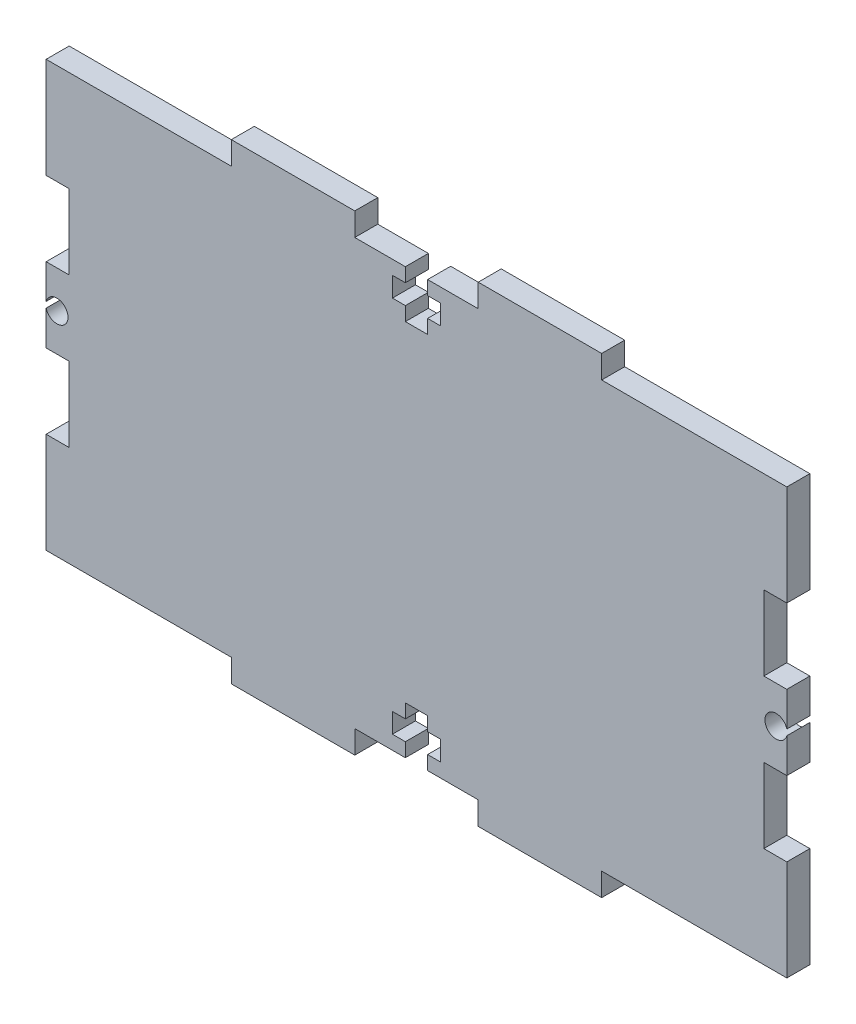
from build123d import *

# Parameters (mm, degrees)
SKETCH1_W           = 96.52
SKETCH1_H           = 55.42
BOSS_EXTRUDE1_DEPTH = 3
SKETCH2_W           = 48.26
SKETCH2_H           = 3
BOSS_EXTRUDE2_DEPTH = 3
SKETCH4_W           = 3
SKETCH4_H           = 29.21
CUT_EXTRUDE1_DEPTH  = 3
SKETCH5_W           = 16.086666666
SKETCH5_H           = 3
CUT_EXTRUDE2_DEPTH  = 3
SKETCH6_W           = 3
SKETCH6_H           = 9.737913064
BOSS_EXTRUDE3_DEPTH = 3
SKETCH7_W           = 2.9
SKETCH7_H           = 3
CUT_EXTRUDE3_DEPTH  = 6.2
SKETCH9_W           = 6.27
SKETCH9_H           = 2.573555094
CUT_EXTRUDE4_DEPTH  = 3
SKETCH10_R          = 1.45
CUT_EXTRUDE5_DEPTH  = 3


with BuildPart() as part:
    # Sketch1 → Boss-Extrude1 (new body)
    with BuildSketch(Plane.XY):
        Rectangle(SKETCH1_W, SKETCH1_H)
    extrude(amount=BOSS_EXTRUDE1_DEPTH)

    # Sketch2 → Boss-Extrude2 (add)
    with BuildSketch(Plane(origin=(0, 27.71, 0), x_dir=(1, 0, 0), z_dir=(0, 1, 0))):
        with Locations((0, -1.5)):
            Rectangle(SKETCH2_W, SKETCH2_H)
    boss_extrude2 = extrude(amount=BOSS_EXTRUDE2_DEPTH)

    # Mirror1: Boss-Extrude2 across plane
    add(boss_extrude2.mirror(Plane.ZX))

    # Sketch4 → Cut-Extrude1 (cut)
    with BuildSketch(Plane(origin=(48.26, 0, 0), x_dir=(0, 0, -1), z_dir=(1, 0, 0))):
        with Locations((-1.5, 0)):
            Rectangle(SKETCH4_W, SKETCH4_H)
    cut_extrude1 = extrude(amount=-CUT_EXTRUDE1_DEPTH, mode=Mode.SUBTRACT)

    # Mirror2: Cut-Extrude1 across plane
    add(cut_extrude1.mirror(Plane(origin=(0, 0, 0), x_dir=(0, 0, 1), z_dir=(1, 0, 0))), mode=Mode.SUBTRACT)

    # Sketch5 → Cut-Extrude2 (cut)
    with BuildSketch(Plane(origin=(0, 30.71, 0), x_dir=(1, 0, 0), z_dir=(0, 1, 0))):
        with Locations((0, -1.5)):
            Rectangle(SKETCH5_W, SKETCH5_H)
    cut_extrude2 = extrude(amount=-CUT_EXTRUDE2_DEPTH, mode=Mode.SUBTRACT)

    # Mirror3: Cut-Extrude2 across plane
    add(cut_extrude2.mirror(Plane.ZX), mode=Mode.SUBTRACT)

    # Sketch6 → Boss-Extrude3 (add)
    with BuildSketch(Plane.ZY.offset(45.26)):
        with Locations((1.5, 0)):
            Rectangle(SKETCH6_W, SKETCH6_H)
    boss_extrude3 = extrude(amount=BOSS_EXTRUDE3_DEPTH)

    # Mirror4: Boss-Extrude3 across plane
    add(boss_extrude3.mirror(Plane(origin=(0, 0, 0), x_dir=(0, 0, 1), z_dir=(1, 0, 0))))

    # Sketch7 → Cut-Extrude3 (cut)
    with BuildSketch(Plane.XZ.offset(27.71)):
        with Locations((0, 1.5)):
            Rectangle(SKETCH7_W, SKETCH7_H)
    cut_extrude3 = extrude(amount=-CUT_EXTRUDE3_DEPTH, mode=Mode.SUBTRACT)

    # Sketch9 → Cut-Extrude4 (cut)
    with BuildSketch(Plane(origin=(0, 0, 0), x_dir=(-1, 0, 0), z_dir=(0, 0, -1))):
        with Locations((0, -24.61)):
            Rectangle(SKETCH9_W, SKETCH9_H)
    cut_extrude4 = extrude(amount=-CUT_EXTRUDE4_DEPTH, mode=Mode.SUBTRACT)

    # Mirror5: Cut-Extrude3 across plane
    add(cut_extrude3.mirror(Plane.ZX), mode=Mode.SUBTRACT)

    # Mirror6: Cut-Extrude4 across plane
    add(cut_extrude4.mirror(Plane.ZX), mode=Mode.SUBTRACT)

    # Sketch10 → Cut-Extrude5 (cut)
    with BuildSketch(Plane(origin=(0, 0, 0), x_dir=(-1, 0, 0), z_dir=(0, 0, -1))):
        with Locations((46.86, 0.006629449)):
            Circle(SKETCH10_R)
    cut_extrude5 = extrude(amount=-CUT_EXTRUDE5_DEPTH, mode=Mode.SUBTRACT)

    # Mirror7: Cut-Extrude5 across plane
    add(cut_extrude5.mirror(Plane(origin=(0, 0, 0), x_dir=(0, 0, 1), z_dir=(1, 0, 0))), mode=Mode.SUBTRACT)


solid = part.part
